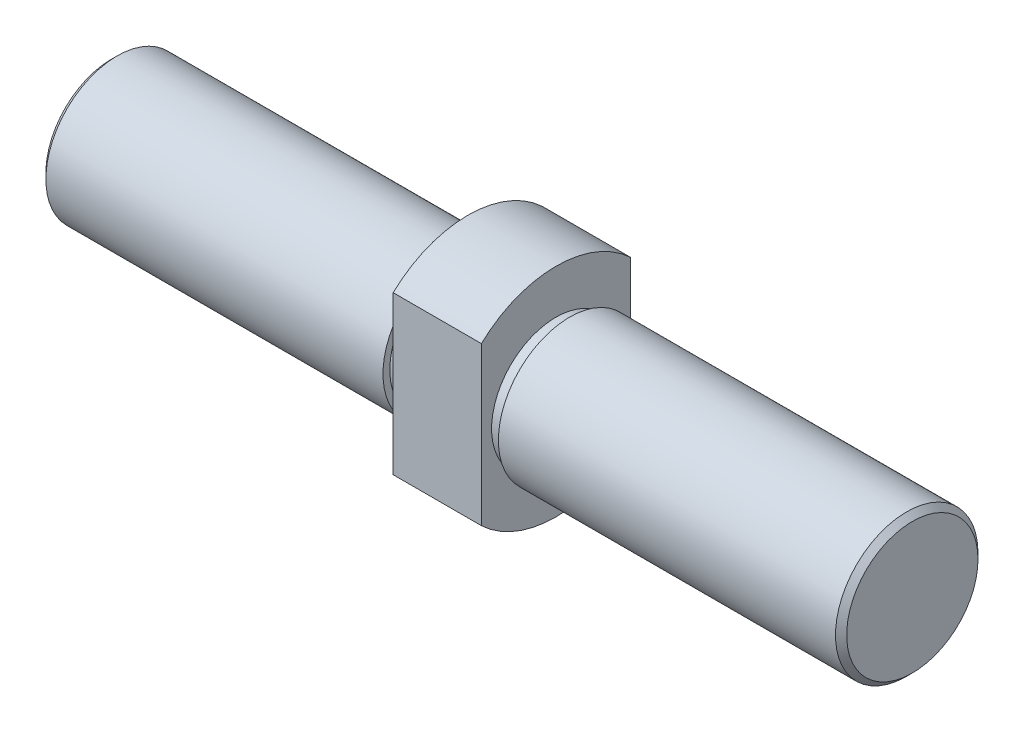
from build123d import *

# Parameters (mm, degrees)
EXTRUDE_1_DEPTH = 13
SKETCH_2_R      = 19
EXTRUDE_2_DEPTH = 105
SKETCH_3_R      = 21
EXTRUDE_3_DEPTH = 101
CHAMFER_1_SIZE  = 1.648


with BuildPart() as part:
    # Эскиз1 → Бобышка-Вытянуть1 (new body)
    with BuildSketch(Plane(origin=(0, 0, 0), x_dir=(0, 0, -1), z_dir=(1, 0, 0))):
        with BuildLine():
            Line((22, -23.237900077), (22, 23.237900077))
            ThreePointArc((22, 23.237900077), (0, 32), (-22, 23.237900077))
            Line((-22, 23.237900077), (-22, -23.237900077))
            ThreePointArc((-22, -23.237900077), (0, -32), (22, -23.237900077))
        make_face()
    extrude(amount=EXTRUDE_1_DEPTH)

    # Эскиз2 → Бобышка-Вытянуть2 (add)
    with BuildSketch(Plane(origin=(13, 0, 0), x_dir=(0, 0, -1), z_dir=(1, 0, 0))):
        Circle(SKETCH_2_R)
    extrude(amount=EXTRUDE_2_DEPTH)

    # Эскиз3 → Бобышка-Вытянуть3 (add)
    with BuildSketch(Plane(origin=(118, 0, 0), x_dir=(0, 0, -1), z_dir=(1, 0, 0))):
        Circle(SKETCH_3_R)
    extrude(amount=-EXTRUDE_3_DEPTH)

    # Фаска1
    chamfer_1_edges = [part.edges().sort_by_distance(p)[0] for p in [
        (118, 0, 21),
    ]]
    chamfer(chamfer_1_edges, length=CHAMFER_1_SIZE)

    # Зеркальное отражение4: part across plane


with BuildPart() as part_1:
    add(part.part)
    add(part.part.mirror(Plane(origin=(0, 0, 0), x_dir=(0, 0, 1), z_dir=(1, 0, 0))))


solid = part_1.part
